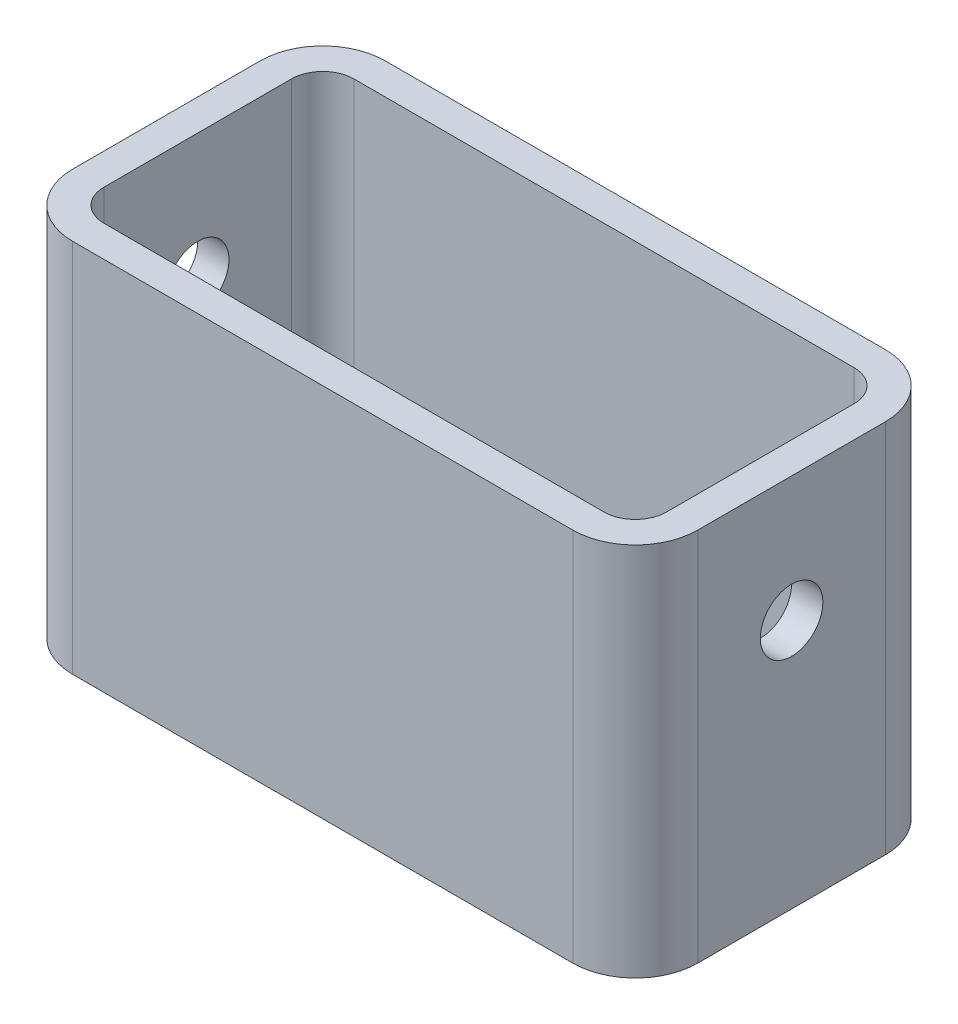
from build123d import *

# Parameters (mm, degrees)
SKETCH1_W           = 100
SKETCH1_H           = 50
BOSS_EXTRUDE1_DEPTH = 60
FILLET2_R           = 10
CUT_EXTRUDE1_DEPTH  = 80
SKETCH2_R           = 5
CUT_EXTRUDE2_DEPTH  = 127.885775404


with BuildPart() as part:
    # Sketch1 → Boss-Extrude1 (new body)
    with BuildSketch(Plane(origin=(0, 0, 0), x_dir=(1, 0, 0), z_dir=(0, 1, 0))):
        with Locations((50, 25)):
            Rectangle(SKETCH1_W, SKETCH1_H)
    extrude(amount=BOSS_EXTRUDE1_DEPTH)

    # Fillet2
    fillet2_edges = [part.edges().sort_by_distance(p)[0] for p in [
        (0, 30, -50),
        (100, 30, -50),
        (100, 30, 0),
        (0, 30, 0),
    ]]
    fillet(fillet2_edges, radius=FILLET2_R)

    # 3DSketch1 → Cut-Extrude1 (cut)
    with BuildSketch(Plane(origin=(10, 60, -5), x_dir=(0.924678098474716, 0, -0.38074980525429475), z_dir=(0, 1, 0))):
        with BuildLine():
            Line((0, 0), (73.974247878, -30.45998442))
            ThreePointArc((73.974247878, -30.45998442), (77.801073827, -30.451978543), (80.501387397, -27.740342954))
            Line((80.501387397, -27.740342954), (91.923881554, 0))
            ThreePointArc((91.923881554, 0), (91.915875677, 3.826825949), (89.204240088, 6.527139519))
            Line((89.204240088, 6.527139519), (15.22999221, 36.987123939))
            ThreePointArc((15.22999221, 36.987123939), (11.403166261, 36.979118062), (8.702852692, 34.267482473))
            Line((8.702852692, 34.267482473), (-2.719641466, 6.527139519))
            ThreePointArc((-2.719641466, 6.527139519), (-2.711635589, 2.700313569), (0, 0))
        make_face()
    extrude(amount=-CUT_EXTRUDE1_DEPTH, mode=Mode.SUBTRACT)

    # Sketch2 → Cut-Extrude2 (cut, through all)
    with BuildSketch(Plane.ZY):
        with Locations((-25, 40)):
            Circle(SKETCH2_R)
    extrude(amount=-CUT_EXTRUDE2_DEPTH, mode=Mode.SUBTRACT)


solid = part.part
